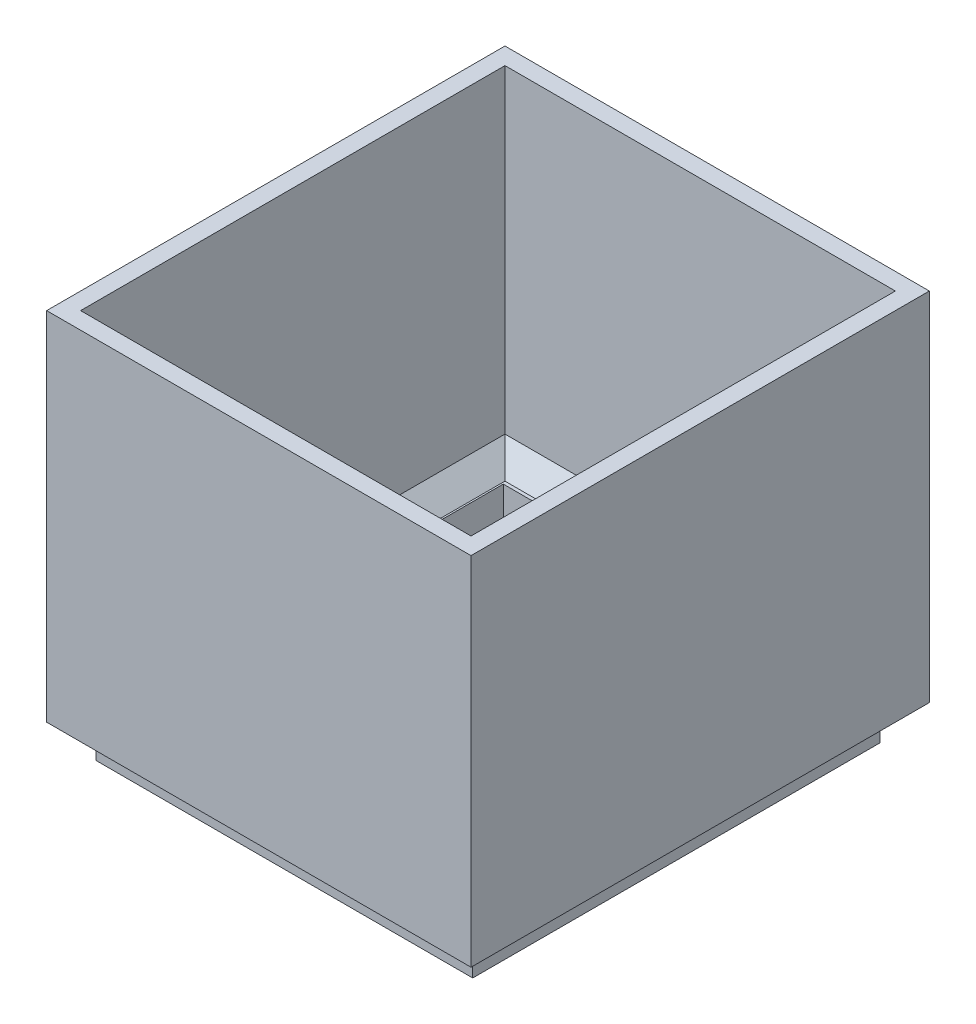
from build123d import *

# Parameters (mm, degrees)
SKETCH1_W           = 111
SKETCH1_H           = 120
SKETCH1_W_2         = 102
SKETCH1_H_2         = 111
BOSS_EXTRUDE1_DEPTH = 10
SKETCH2_W           = 125
SKETCH2_H           = 135
SKETCH2_W_2         = 102
SKETCH2_H_2         = 111
BOSS_EXTRUDE2_DEPTH = 5
SKETCH4_W           = 125
SKETCH4_H           = 135
SKETCH4_W_2         = 115
SKETCH4_H_2         = 125
BOSS_EXTRUDE4_DEPTH = 100
CHAMFER1_SIZE       = 6


with BuildPart() as part:
    # Sketch1 → Boss-Extrude1 (new body)
    with BuildSketch(Plane(origin=(0, 0, 0), x_dir=(1, 0, 0), z_dir=(0, 1, 0))):
        Rectangle(SKETCH1_W, SKETCH1_H)
        Rectangle(SKETCH1_W_2, SKETCH1_H_2, mode=Mode.SUBTRACT)
    extrude(amount=BOSS_EXTRUDE1_DEPTH)

    # Sketch2 → Boss-Extrude2 (add)
    with BuildSketch(Plane(origin=(0, 10, 0), x_dir=(1, 0, 0), z_dir=(0, 1, 0))):
        Rectangle(SKETCH2_W, SKETCH2_H)
        Rectangle(SKETCH2_W_2, SKETCH2_H_2, mode=Mode.SUBTRACT)
    extrude(amount=BOSS_EXTRUDE2_DEPTH)

    # Sketch4 → Boss-Extrude4 (add)
    with BuildSketch(Plane(origin=(0, 15, 0), x_dir=(1, 0, 0), z_dir=(0, 1, 0))):
        Rectangle(SKETCH4_W, SKETCH4_H)
        Rectangle(SKETCH4_W_2, SKETCH4_H_2, mode=Mode.SUBTRACT)
    extrude(amount=BOSS_EXTRUDE4_DEPTH)

    # Chamfer1
    chamfer1_edges = [part.edges().sort_by_distance(p)[0] for p in [
        (0, 15, -62.5),
        (-57.5, 15, 0),
        (0, 15, 62.5),
        (57.5, 15, 0),
    ]]
    chamfer(chamfer1_edges, length=CHAMFER1_SIZE)


solid = part.part
